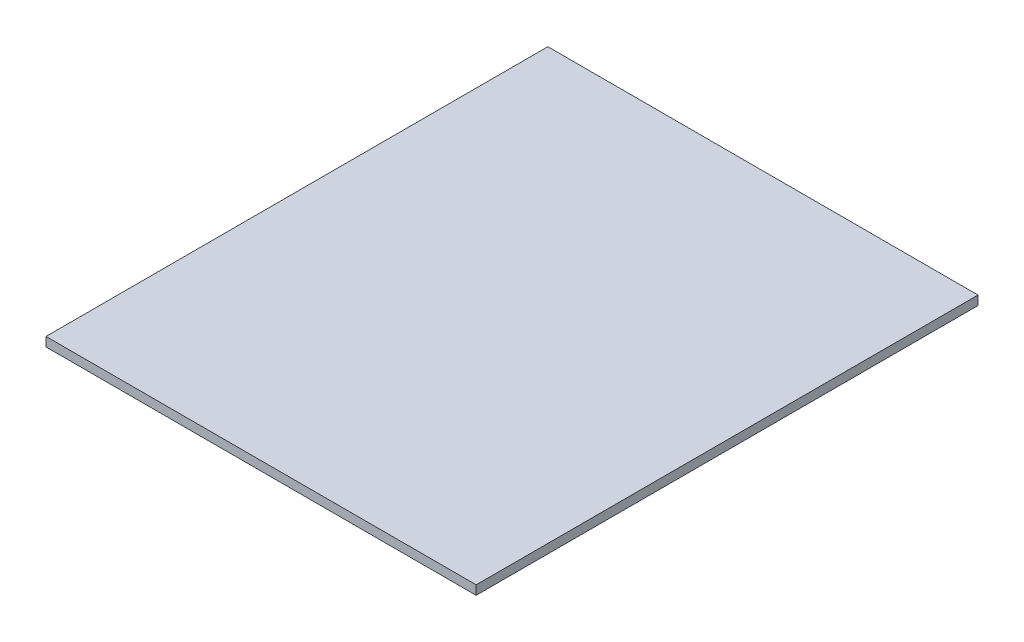
from build123d import *

# Parameters (mm, degrees)
CROQUIS1_W              = 600
CROQUIS1_H              = 700
SALIENTE_EXTRUIR1_DEPTH = 12.7


with BuildPart() as part:
    # Croquis1 → Saliente-Extruir1 (new body)
    with BuildSketch(Plane(origin=(0, 0, 0), x_dir=(1, 0, 0), z_dir=(0, 1, 0))):
        Rectangle(CROQUIS1_W, CROQUIS1_H)
    extrude(amount=SALIENTE_EXTRUIR1_DEPTH)


solid = part.part
